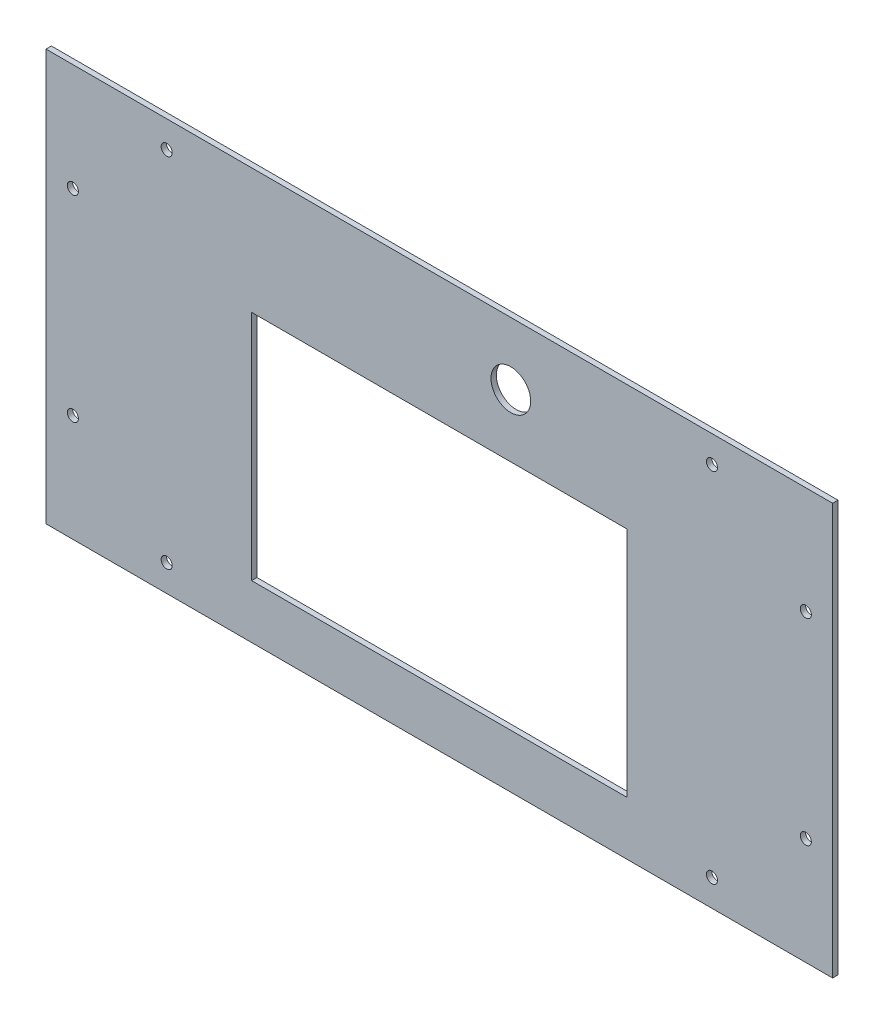
from build123d import *

# Parameters (mm, degrees)
CROQUIS1_W              = 440
CROQUIS1_H              = 230
SALIENTE_EXTRUIR1_DEPTH = 3
CROQUIS2_R              = 3.1
CORTAR_EXTRUIR1_DEPTH   = 4
CROQUIS3_W              = 210
CROQUIS3_H              = 130
CORTAR_EXTRUIR2_DEPTH   = 4
CROQUIS4_R              = 11.1
CORTAR_EXTRUIR3_DEPTH   = 4


with BuildPart() as part:
    # Croquis1 → Saliente-Extruir1 (new body)
    with BuildSketch(Plane.XY):
        Rectangle(CROQUIS1_W, CROQUIS1_H)
    extrude(amount=SALIENTE_EXTRUIR1_DEPTH)

    # Croquis2 → Cortar-Extruir1 (cut, through all)
    with BuildSketch(Plane.XY.offset(3)):
        with Locations((-205, 55)):
            Circle(CROQUIS2_R)
        with Locations((-152.5, 100)):
            Circle(CROQUIS2_R)
        with Locations((152.5, 100)):
            Circle(CROQUIS2_R)
        with Locations((-205, -55)):
            Circle(CROQUIS2_R)
        with Locations((205, -55)):
            Circle(CROQUIS2_R)
        with Locations((205, 55)):
            Circle(CROQUIS2_R)
        with Locations((152.5, -100)):
            Circle(CROQUIS2_R)
        with Locations((-152.5, -100)):
            Circle(CROQUIS2_R)
    extrude(amount=-CORTAR_EXTRUIR1_DEPTH, mode=Mode.SUBTRACT)

    # Croquis3 → Cortar-Extruir2 (cut, through all)
    with BuildSketch(Plane(origin=(0, 0, 0), x_dir=(-1, 0, 0), z_dir=(0, 0, -1))):
        with Locations((0, -20)):
            Rectangle(CROQUIS3_W, CROQUIS3_H)
    extrude(amount=-CORTAR_EXTRUIR2_DEPTH, mode=Mode.SUBTRACT)

    # Croquis4 → Cortar-Extruir3 (cut, through all)
    with BuildSketch(Plane(origin=(0, 0, 0), x_dir=(-1, 0, 0), z_dir=(0, 0, -1))):
        with Locations((-40, 80)):
            Circle(CROQUIS4_R)
    extrude(amount=-CORTAR_EXTRUIR3_DEPTH, mode=Mode.SUBTRACT)


solid = part.part
